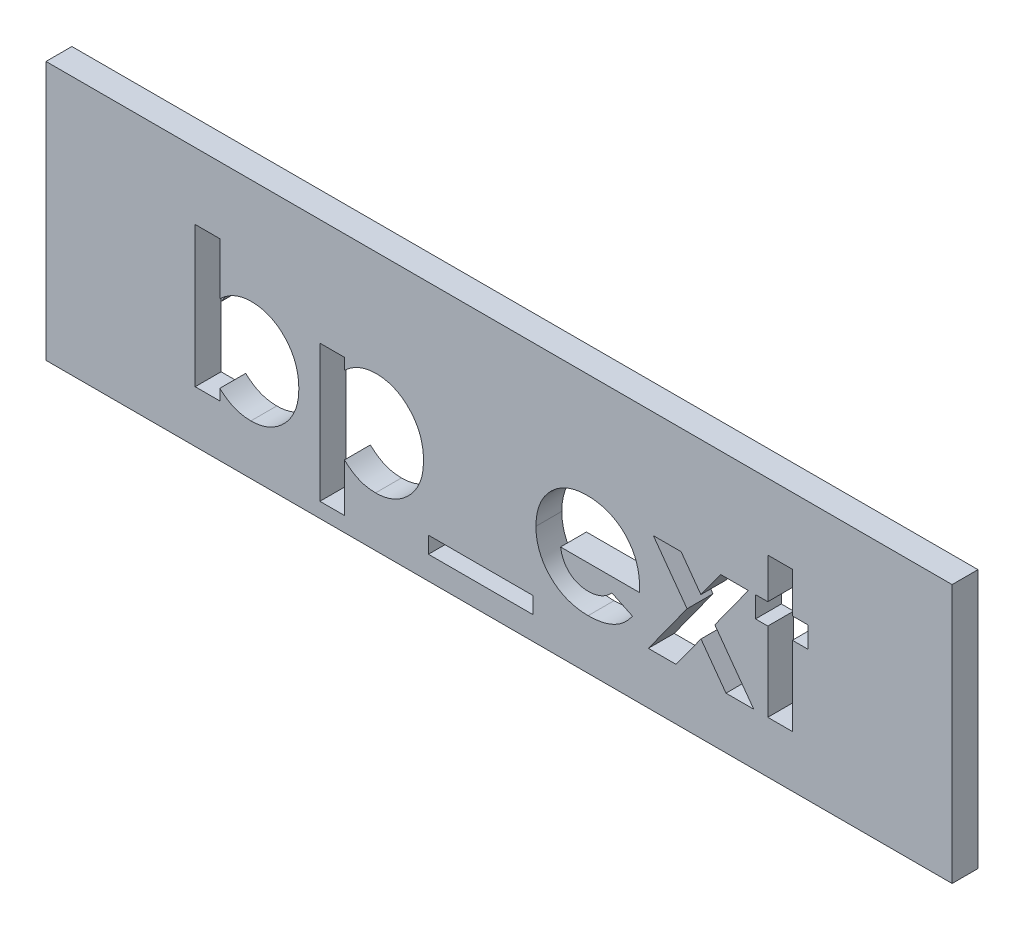
from build123d import *

# Parameters (mm, degrees)
ESQUISSE1_W             = 35
ESQUISSE1_H             = 10
BOSS_EXTRU_1_DEPTH      = 1
ESQUISSE2_R             = 1
BOSS_EXTRU_2_DEPTH      = 3
CHANFREIN1_SIZE         = 0.5
ESQUISSE3_W             = 3.731303419
ESQUISSE3_H             = 0.339209402
ENL_V_MAT_EXTRU_2_DEPTH = 1
ESQUISSE4_W             = 4.031303419
ESQUISSE4_H             = 0.639209402
ENL_V_MAT_EXTRU_3_DEPTH = 5


with BuildPart() as part:
    # Esquisse1 → Boss.-Extru.1 (new body)
    with BuildSketch(Plane.XY):
        with Locations((17.5, -5)):
            Rectangle(ESQUISSE1_W, ESQUISSE1_H)
    extrude(amount=BOSS_EXTRU_1_DEPTH)

    # Esquisse2 → Boss.-Extru.2 (add)
    with BuildSketch(Plane(origin=(0, 0, 0), x_dir=(-1, 0, 0), z_dir=(0, 0, -1))):
        with Locations(Location((-30, -5, 0), (0, 0, 180))):  # turned: the seam where the file's is
            Circle(ESQUISSE2_R)
        with Locations(Location((-5, -5, 0), (0, 0, 180))):  # turned: the seam where the file's is
            Circle(ESQUISSE2_R)
    extrude(amount=BOSS_EXTRU_2_DEPTH)

    # Chanfrein1
    chanfrein1_edges = [part.edges().sort_by_distance(p)[0] for p in [
        (29, -5, -3),
        (4, -5, -3),
    ]]
    chamfer(chanfrein1_edges, length=CHANFREIN1_SIZE)

    # Esquisse3 → Enlèv. mat.-Extru.2 (cut)
    with BuildSketch(Plane.XY.offset(1)):
        with BuildLine():
            Line((6.713141026, -2.572649573), (6.713141026, -4.583525307))
            add(Edge.make_bspline(
                [(6.713141026, -4.583525307), (6.757244759, -4.541998984), (6.843822735, -4.460480601), (6.98518027, -4.35506841), (7.13160984, -4.266101384), (7.282980265, -4.191462211), (7.440653893, -4.136269762), (7.602693418, -4.09338316), (7.770759214, -4.070669512), (7.884415009, -4.067013922), (7.941715077, -4.06517094)],
                knots=[0, 0, 0, 0, 1.061187343, 2.083167259, 3.083809127, 4.061667593, 5.035358583, 6.007314429, 6.995378812, 8, 8, 8, 8], degree=3))
            add(Edge.make_bspline(
                [(7.941715077, -4.06517094), (8.004001029, -4.066662846), (8.126684142, -4.069601416), (8.307189001, -4.097037187), (8.480170316, -4.141385223), (8.646287709, -4.203307169), (8.804656126, -4.283702473), (8.957054949, -4.379960671), (9.100855881, -4.496053903), (9.236128828, -4.627548954), (9.361259675, -4.771677298), (9.470100466, -4.928375398), (9.560760622, -5.095580805), (9.637599558, -5.271316802), (9.6936797, -5.458497913), (9.736901594, -5.654613228), (9.76098726, -5.861321926), (9.764324411, -6.002139788), (9.766025641, -6.073926616)],
                knots=[0, 0, 0, 0, 0.985987466, 1.942075377, 2.884088208, 3.810275091, 4.743821533, 5.692411115, 6.659945104, 7.665215984, 8.677116751, 9.678438675, 10.680260931, 11.685531812, 12.710472044, 13.769734641, 14.863044265, 16, 16, 16, 16], degree=3))
            add(Edge.make_bspline(
                [(9.766025641, -6.073926616), (9.76441554, -6.14325599), (9.761241677, -6.279919471), (9.735598863, -6.480552708), (9.69213644, -6.672214326), (9.631167468, -6.854973348), (9.553659479, -7.029407327), (9.459055629, -7.195396066), (9.346804073, -7.352359771), (9.218471578, -7.498183983), (9.078249677, -7.630238647), (8.932148507, -7.748717936), (8.777258213, -7.845802422), (8.617450707, -7.927797708), (8.450208414, -7.990497917), (8.276673673, -8.03442646), (8.097121321, -8.063795417), (7.97504759, -8.066479625), (7.913094284, -8.06784188)],
                knots=[0, 0, 0, 0, 1.098553145, 2.165490463, 3.199345634, 4.208780719, 5.21409072, 6.219899742, 7.23156933, 8.267303578, 9.293302409, 10.281606823, 11.243293419, 12.184993323, 13.124258899, 14.066907486, 15.018941492, 16, 16, 16, 16], degree=3))
            add(Edge.make_bspline(
                [(7.913094284, -8.06784188), (7.857907821, -8.0663666), (7.749241662, -8.063461667), (7.589063222, -8.041916446), (7.435137556, -8.005681537), (7.285520218, -7.955767715), (7.139805247, -7.887570758), (6.995455014, -7.802299386), (6.851540512, -7.698874718), (6.760202835, -7.619174108), (6.713141026, -7.578108307)],
                knots=[0, 0, 0, 0, 0.996418773, 1.962021009, 2.912343664, 3.848616743, 4.805003894, 5.811808768, 6.872532775, 8, 8, 8, 8], degree=3))
            Line((6.713141026, -7.578108307), (6.713141026, -8))
            Line((6.713141026, -8), (5.763354701, -8))
            Line((5.763354701, -8), (5.763354701, -2.572649573))
            Line((5.763354701, -2.572649573), (6.713141026, -2.572649573))
        make_face()
        with BuildLine():
            add(Edge.make_bspline(
                [(7.736069378, -4.947115385), (7.697524215, -4.948300675), (7.621954743, -4.950624488), (7.511004993, -4.963942252), (7.405878152, -4.988999721), (7.304975851, -5.021476766), (7.209575803, -5.065315677), (7.118897528, -5.118457449), (7.033717694, -5.181824954), (6.95359422, -5.25290892), (6.881596908, -5.332878514), (6.817633542, -5.418330174), (6.764567409, -5.51037664), (6.720331004, -5.607850774), (6.686956569, -5.711807237), (6.662202407, -5.821361669), (6.64875009, -5.936849805), (6.646467654, -6.015593011), (6.645299145, -6.055906116)],
                knots=[0, 0, 0, 0, 1.060469436, 2.079096586, 3.066888298, 4.028858836, 4.99004353, 5.948472697, 6.914558426, 7.905691313, 8.889602648, 9.869280844, 10.836099585, 11.806137001, 12.808075328, 13.83377171, 14.890985086, 16, 16, 16, 16], degree=3))
            add(Edge.make_bspline(
                [(6.645299145, -6.055906116), (6.646482357, -6.096924734), (6.648804461, -6.177425538), (6.662144636, -6.295376304), (6.686725049, -6.407125617), (6.720802412, -6.512926841), (6.764286076, -6.612793704), (6.817289335, -6.707096426), (6.881956772, -6.793767468), (6.953163167, -6.875845516), (7.033782065, -6.9478806), (7.118578161, -7.012486161), (7.209553773, -7.065707146), (7.305409741, -7.108828725), (7.405418718, -7.14466252), (7.51107103, -7.168875378), (7.62193722, -7.182440126), (7.697518296, -7.18472964), (7.736069378, -7.185897436)],
                knots=[0, 0, 0, 0, 1.117193555, 2.192540452, 3.22680955, 4.227918444, 5.21468246, 6.188555072, 7.166222992, 8.154674427, 9.142376254, 10.104580718, 11.053462639, 12.005072638, 12.963662044, 13.941614018, 14.950094269, 16, 16, 16, 16], degree=3))
            add(Edge.make_bspline(
                [(7.736069378, -7.185897436), (7.773218175, -7.184812589), (7.846751485, -7.182665216), (7.954343175, -7.167681595), (8.057765593, -7.14319687), (8.156208807, -7.10829728), (8.250272078, -7.062858049), (8.340811731, -7.009686628), (8.424701997, -6.943252907), (8.505234031, -6.870236576), (8.577288686, -6.787895155), (8.641930372, -6.70041824), (8.696231309, -6.607025082), (8.739344973, -6.507405975), (8.774988268, -6.403447851), (8.79932307, -6.293247915), (8.812711632, -6.177789782), (8.815051739, -6.099047168), (8.816239316, -6.059086205)],
                knots=[0, 0, 0, 0, 1.021711385, 2.02240246, 2.981887075, 3.941027022, 4.888772411, 5.852236371, 6.822344989, 7.82661704, 8.838806642, 9.826383926, 10.814965113, 11.80282933, 12.807900643, 13.833672313, 14.900613836, 16, 16, 16, 16], degree=3))
            add(Edge.make_bspline(
                [(8.816239316, -6.059086205), (8.815032774, -6.019484756), (8.812655548, -5.941458813), (8.799541155, -5.826962137), (8.774269426, -5.718364319), (8.742360652, -5.614778194), (8.697781233, -5.517552184), (8.645070566, -5.425536121), (8.5830467, -5.338452168), (8.511096343, -5.258651167), (8.432179482, -5.186037989), (8.347937078, -5.121811034), (8.258699957, -5.067135595), (8.163252906, -5.024017819), (8.063848324, -4.988541182), (7.958967102, -4.964104405), (7.849142446, -4.950579726), (7.774266624, -4.948285675), (7.736069378, -4.947115385)],
                knots=[0, 0, 0, 0, 1.094680664, 2.156827393, 3.177782763, 4.17210342, 5.146667393, 6.126451192, 7.099203661, 8.094961544, 9.09004898, 10.058676268, 11.018205477, 11.974998356, 12.947750825, 13.930643515, 14.944335875, 16, 16, 16, 16], degree=3))
        make_face(mode=Mode.SUBTRACT)
        with BuildLine():
            Line((11.52991453, -4.133012821), (11.52991453, -4.568684896))
            add(Edge.make_bspline(
                [(11.52991453, -4.568684896), (11.574008936, -4.528171753), (11.660605798, -4.448608122), (11.80238829, -4.346742923), (11.948091202, -4.259256524), (12.100391671, -4.188889417), (12.257199577, -4.133445707), (12.41992001, -4.09448843), (12.587356642, -4.068795061), (12.701151597, -4.066385185), (12.758488582, -4.06517094)],
                knots=[0, 0, 0, 0, 1.054376801, 2.070687235, 3.070225973, 4.045259405, 5.022040922, 5.996139433, 6.99033025, 8, 8, 8, 8], degree=3))
            add(Edge.make_bspline(
                [(12.758488582, -4.06517094), (12.820774533, -4.066662846), (12.943457647, -4.069601416), (13.123962505, -4.097037187), (13.29694382, -4.141385223), (13.463061213, -4.203307169), (13.62142963, -4.283702473), (13.773828453, -4.379960671), (13.917629385, -4.496053903), (14.052902333, -4.627548954), (14.178033179, -4.771677298), (14.286873971, -4.928375398), (14.377534126, -5.095580805), (14.454373062, -5.271316802), (14.510453205, -5.458497913), (14.553675099, -5.654613228), (14.577760764, -5.861321926), (14.581097916, -6.002139788), (14.582799145, -6.073926616)],
                knots=[0, 0, 0, 0, 0.985987466, 1.942075377, 2.884088208, 3.810275091, 4.743821533, 5.692411115, 6.659945104, 7.665215984, 8.677116751, 9.678438675, 10.680260931, 11.685531812, 12.710472044, 13.769734641, 14.863044265, 16, 16, 16, 16], degree=3))
            add(Edge.make_bspline(
                [(14.582799145, -6.073926616), (14.581189045, -6.14325599), (14.578015181, -6.279919471), (14.552372367, -6.480552708), (14.508909944, -6.672214326), (14.447940972, -6.854973348), (14.370432984, -7.029407327), (14.275829134, -7.195396066), (14.163577578, -7.352359771), (14.035245082, -7.498183983), (13.895023181, -7.630238647), (13.748922011, -7.748717936), (13.594031718, -7.845802422), (13.434224212, -7.927797708), (13.266981919, -7.990497917), (13.093447177, -8.03442646), (12.913894825, -8.063795417), (12.791821094, -8.066479625), (12.729867788, -8.06784188)],
                knots=[0, 0, 0, 0, 1.098553145, 2.165490463, 3.199345634, 4.208780719, 5.21409072, 6.219899742, 7.23156933, 8.267303578, 9.293302409, 10.281606823, 11.243293419, 12.184993323, 13.124258899, 14.066907486, 15.018941492, 16, 16, 16, 16], degree=3))
            add(Edge.make_bspline(
                [(12.729867788, -8.06784188), (12.674660223, -8.066502987), (12.565904641, -8.063865449), (12.405982089, -8.040348446), (12.251495088, -8.005222037), (12.102239282, -7.952352875), (11.956536771, -7.882195943), (11.811906057, -7.794828168), (11.668012702, -7.688093559), (11.576934896, -7.605769171), (11.52991453, -7.563267895)],
                knots=[0, 0, 0, 0, 0.990856396, 1.951927477, 2.896945079, 3.83213376, 4.788585491, 5.796263726, 6.862286081, 8, 8, 8, 8], degree=3))
            Line((11.52991453, -7.563267895), (11.52991453, -9.424679487))
            Line((11.52991453, -9.424679487), (10.580128205, -9.424679487))
            Line((10.580128205, -9.424679487), (10.580128205, -4.133012821))
            Line((10.580128205, -4.133012821), (11.52991453, -4.133012821))
        make_face()
        with BuildLine():
            add(Edge.make_bspline(
                [(12.552842882, -4.947115385), (12.514297719, -4.948300675), (12.438728247, -4.950624488), (12.327778497, -4.963942252), (12.222651656, -4.988999721), (12.121749355, -5.021476766), (12.026349308, -5.065315677), (11.935671033, -5.118457449), (11.850491199, -5.181824954), (11.770367724, -5.25290892), (11.698370412, -5.332878514), (11.634407046, -5.418330174), (11.581340914, -5.51037664), (11.537104509, -5.607850774), (11.503730073, -5.711807237), (11.478975912, -5.821361669), (11.465523594, -5.936849805), (11.463241158, -6.015593011), (11.46207265, -6.055906116)],
                knots=[0, 0, 0, 0, 1.060469436, 2.079096586, 3.066888298, 4.028858836, 4.99004353, 5.948472697, 6.914558426, 7.905691313, 8.889602648, 9.869280844, 10.836099585, 11.806137001, 12.808075328, 13.83377171, 14.890985086, 16, 16, 16, 16], degree=3))
            add(Edge.make_bspline(
                [(11.46207265, -6.055906116), (11.463255861, -6.096924734), (11.465577965, -6.177425538), (11.47891814, -6.295376304), (11.503498553, -6.407125617), (11.537575917, -6.512926841), (11.58105958, -6.612793704), (11.634062839, -6.707096426), (11.698730276, -6.793767468), (11.769936671, -6.875845516), (11.850555569, -6.9478806), (11.935351666, -7.012486161), (12.026327278, -7.065707146), (12.122183245, -7.108828725), (12.222192223, -7.14466252), (12.327844534, -7.168875378), (12.438710724, -7.182440126), (12.514291801, -7.18472964), (12.552842882, -7.185897436)],
                knots=[0, 0, 0, 0, 1.117193555, 2.192540452, 3.22680955, 4.227918444, 5.21468246, 6.188555072, 7.166222992, 8.154674427, 9.142376254, 10.104580718, 11.053462639, 12.005072638, 12.963662044, 13.941614018, 14.950094269, 16, 16, 16, 16], degree=3))
            add(Edge.make_bspline(
                [(12.552842882, -7.185897436), (12.58999168, -7.184812589), (12.663524989, -7.182665216), (12.771116679, -7.167681595), (12.874539098, -7.14319687), (12.972982311, -7.10829728), (13.067045582, -7.062858049), (13.157585235, -7.009686628), (13.241475501, -6.943252907), (13.322007535, -6.870236576), (13.394062191, -6.787895155), (13.458703876, -6.70041824), (13.513004813, -6.607025082), (13.556118477, -6.507405975), (13.591761772, -6.403447851), (13.616096574, -6.293247915), (13.629485137, -6.177789782), (13.631825243, -6.099047168), (13.633012821, -6.059086205)],
                knots=[0, 0, 0, 0, 1.021711385, 2.02240246, 2.981887075, 3.941027022, 4.888772411, 5.852236371, 6.822344989, 7.82661704, 8.838806642, 9.826383926, 10.814965113, 11.80282933, 12.807900643, 13.833672313, 14.900613836, 16, 16, 16, 16], degree=3))
            add(Edge.make_bspline(
                [(13.633012821, -6.059086205), (13.631806278, -6.019484756), (13.629429053, -5.941458813), (13.61631466, -5.826962137), (13.591042931, -5.718364319), (13.559134156, -5.614778194), (13.514554738, -5.517552184), (13.46184407, -5.425536121), (13.399820204, -5.338452168), (13.327869847, -5.258651167), (13.248952987, -5.186037989), (13.164710582, -5.121811034), (13.075473461, -5.067135595), (12.98002641, -5.024017819), (12.880621828, -4.988541182), (12.775740606, -4.964104405), (12.66591595, -4.950579726), (12.591040128, -4.948285675), (12.552842882, -4.947115385)],
                knots=[0, 0, 0, 0, 1.094680664, 2.156827393, 3.177782763, 4.17210342, 5.146667393, 6.126451192, 7.099203661, 8.094961544, 9.09004898, 10.058676268, 11.018205477, 11.974998356, 12.947750825, 13.930643515, 14.944335875, 16, 16, 16, 16], degree=3))
        make_face(mode=Mode.SUBTRACT)
        with Locations((16.787660257, -8.780181624)):
            Rectangle(ESQUISSE3_W, ESQUISSE3_H)
        with BuildLine():
            Line((22.924170339, -6.303952991), (19.874465812, -6.303952991))
            add(Edge.make_bspline(
                [(19.874465812, -6.303952991), (19.880683913, -6.339388828), (19.892902973, -6.409023042), (19.919437095, -6.510172781), (19.953298615, -6.605494587), (19.993879513, -6.695115884), (20.040495598, -6.779510462), (20.094869398, -6.858282479), (20.156311232, -6.931362358), (20.22446586, -6.998432487), (20.298197267, -7.058528775), (20.377147884, -7.111176923), (20.461399183, -7.154345184), (20.549985254, -7.190731548), (20.643568039, -7.219553234), (20.742285268, -7.239431004), (20.845875258, -7.251172875), (20.916443923, -7.252871202), (20.952515692, -7.253739316)],
                knots=[0, 0, 0, 0, 1.091296461, 2.144483647, 3.168565212, 4.157007626, 5.126487748, 6.090021542, 7.05641414, 8.019231907, 8.98705074, 9.938580405, 10.892824166, 11.854447369, 12.841318655, 13.858982407, 14.905600794, 16, 16, 16, 16], degree=3))
            add(Edge.make_bspline(
                [(20.952515692, -7.253739316), (20.996056765, -7.25258979), (21.081801962, -7.250326034), (21.207419313, -7.23024988), (21.328909589, -7.199925733), (21.445123066, -7.15483118), (21.557405893, -7.098696389), (21.66390955, -7.028759346), (21.766477532, -6.947063841), (21.829056088, -6.884092976), (21.860960871, -6.851988181)],
                knots=[0, 0, 0, 0, 1.021034703, 2.010718019, 2.977989445, 3.954245119, 4.929443971, 5.918328161, 6.938689359, 8, 8, 8, 8], degree=3))
            Line((21.860960871, -6.851988181), (22.655982906, -7.23041867))
            add(Edge.make_bspline(
                [(22.655982906, -7.23041867), (22.630952101, -7.2650074), (22.581354482, -7.333543698), (22.500388033, -7.42999197), (22.415894388, -7.51998212), (22.327810532, -7.602922269), (22.236024752, -7.678576072), (22.140792374, -7.747865128), (22.040721616, -7.808929053), (21.937813374, -7.864722083), (21.829940345, -7.91255319), (21.717401062, -7.953341869), (21.60067219, -7.990214488), (21.478279697, -8.018309404), (21.351242744, -8.04054911), (21.219257434, -8.056342248), (21.082341161, -8.066096912), (20.989279968, -8.067253315), (20.941915398, -8.06784188)],
                knots=[0, 0, 0, 0, 1.028154879, 2.037251081, 3.030720504, 4.000128189, 4.949298328, 5.894184978, 6.834267904, 7.770992897, 8.712077017, 9.673380525, 10.653304757, 11.658697181, 12.695551717, 13.758623199, 14.859225354, 16, 16, 16, 16], degree=3))
            add(Edge.make_bspline(
                [(20.941915398, -8.06784188), (20.869045784, -8.066356288), (20.726334845, -8.063446841), (20.517594299, -8.036443012), (20.319348676, -7.991667753), (20.131038201, -7.930802664), (19.953476876, -7.85044168), (19.786576826, -7.752153529), (19.62867048, -7.637822594), (19.48458276, -7.505049371), (19.353314596, -7.360533612), (19.238016802, -7.205333555), (19.141537251, -7.040533524), (19.062306302, -6.867224201), (19.000725257, -6.684961981), (18.956328895, -6.49366733), (18.929113393, -6.293431612), (18.926173984, -6.157048736), (18.924679487, -6.087706998)],
                knots=[0, 0, 0, 0, 1.103565453, 2.161269334, 3.182010356, 4.179077853, 5.15417608, 6.128274628, 7.109042802, 8.101804412, 9.090965879, 10.063106201, 11.02526161, 11.978650795, 12.945248442, 13.93468508, 14.949922959, 16, 16, 16, 16], degree=3))
            add(Edge.make_bspline(
                [(18.924679487, -6.087706998), (18.926188693, -6.016603197), (18.929157987, -5.876709662), (18.95609457, -5.67185041), (19.000847997, -5.476386975), (19.062609181, -5.290050184), (19.140638186, -5.112257255), (19.238345275, -4.944563662), (19.35325738, -4.786385588), (19.484052653, -4.638463007), (19.628750773, -4.504946716), (19.782506197, -4.385957019), (19.947046523, -4.286806905), (20.12051066, -4.206693674), (20.301789068, -4.141603697), (20.492977071, -4.098291753), (20.692620022, -4.069210375), (20.829091547, -4.066532162), (20.898454193, -4.06517094)],
                knots=[0, 0, 0, 0, 1.079208495, 2.12329425, 3.130605359, 4.119693003, 5.099659317, 6.073216462, 7.060498243, 8.06384408, 9.066070512, 10.045757761, 11.010926815, 11.975797609, 12.942977511, 13.929384301, 14.947594487, 16, 16, 16, 16], degree=3))
            add(Edge.make_bspline(
                [(20.898454193, -4.06517094), (20.971672902, -4.06667958), (21.115430291, -4.06964164), (21.325624651, -4.096426204), (21.525186601, -4.141474498), (21.714966386, -4.201813297), (21.892540441, -4.284204284), (22.061810606, -4.380073719), (22.218716823, -4.496876004), (22.364931544, -4.628999478), (22.496920213, -4.775585892), (22.612292934, -4.934823635), (22.71046092, -5.105158639), (22.790027046, -5.287281648), (22.85154486, -5.480645912), (22.895982318, -5.68500031), (22.922990231, -5.901122106), (22.925874944, -6.049113087), (22.927350427, -6.124808026)],
                knots=[0, 0, 0, 0, 1.080001299, 2.120471247, 3.119684163, 4.095710327, 5.052285597, 6.002875087, 6.961153713, 7.931888285, 8.906493152, 9.865905668, 10.82813294, 11.801621613, 12.7925306, 13.817193356, 14.883530496, 16, 16, 16, 16], degree=3))
            Line((22.927350427, -6.124808026), (22.924170339, -6.303952991))
        make_face()
        with BuildLine():
            add(Edge.make_bspline(
                [(21.977564103, -5.557692308), (21.959641054, -5.509325259), (21.924005364, -5.413158967), (21.843505823, -5.280472948), (21.736685508, -5.165561468), (21.612445818, -5.063829422), (21.470494193, -4.98125734), (21.315303778, -4.921472471), (21.148836148, -4.885624713), (21.034315389, -4.881420401), (20.975836338, -4.879273504)],
                knots=[0, 0, 0, 0, 0.954238005, 1.897273737, 2.851915805, 3.847685534, 4.862635127, 5.880135777, 6.917509367, 8, 8, 8, 8], degree=3))
            add(Edge.make_bspline(
                [(20.975836338, -4.879273504), (20.911967693, -4.88133586), (20.78711779, -4.885367335), (20.607030306, -4.928243552), (20.437158288, -4.992235026), (20.337011374, -5.058211595), (20.286817241, -5.09127938)],
                knots=[0, 0, 0, 0, 1.044195649, 2.041185066, 3.018232172, 4, 4, 4, 4], degree=3))
            add(Edge.make_bspline(
                [(20.286817241, -5.09127938), (20.25549985, -5.11646453), (20.188732775, -5.170157982), (20.102022182, -5.277271321), (20.016611526, -5.40696153), (19.968050859, -5.505470405), (19.942307692, -5.557692308)],
                knots=[0, 0, 0, 0, 0.82159062, 1.751589201, 2.808063854, 4, 4, 4, 4], degree=3))
            Line((19.942307692, -5.557692308), (21.977564103, -5.557692308))
        make_face(mode=Mode.SUBTRACT)
        Polygon((23.460545206, -4.133012821), (24.532234909, -4.133012821), (25.296516092, -5.186682025), (26.057617187, -4.133012821), (27.129306891, -4.133012821), (25.833950988, -5.927642561), (27.33707265, -8), (26.265382946, -8), (25.299696181, -6.668603098), (24.338249533, -8), (23.266559829, -8), (24.762261285, -5.927642561), align=None)
        Polygon((27.879807692, -2.572649573), (28.829594017, -2.572649573), (28.829594017, -4.133012821), (29.44017094, -4.133012821), (29.44017094, -4.947115385), (28.829594017, -4.947115385), (28.829594017, -8), (27.879807692, -8), (27.879807692, -4.947115385), (27.40491453, -4.947115385), (27.40491453, -4.133012821), (27.879807692, -4.133012821), align=None)
    extrude(amount=-ENL_V_MAT_EXTRU_2_DEPTH, mode=Mode.SUBTRACT)


with BuildPart() as body_2:
    # of the pieces the cut leaves, the one that is kept (enl_v_mat_extru_2_keep)
    add(part.part.solids().sort_by_distance((31, -5, -2.5))[0])

    # Esquisse4 → Enlèv. mat.-Extru.3 (cut, through all)
    with BuildSketch(Plane.XY.offset(1)):
        with Locations((16.787660257, -8.780181624)):
            Rectangle(ESQUISSE4_W, ESQUISSE4_H)
    extrude(amount=-ENL_V_MAT_EXTRU_3_DEPTH, mode=Mode.SUBTRACT)


solid = body_2.part
